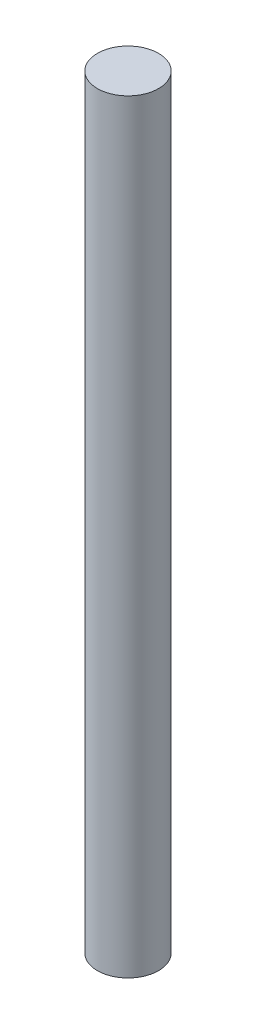
from build123d import *

# Parameters (mm, degrees)
ESQUISSE1_R        = 3
BOSS_EXTRU_1_DEPTH = 75


with BuildPart() as part:
    # Esquisse1 → Boss.-Extru.1 (new body)
    with BuildSketch(Plane(origin=(0, 0, 0), x_dir=(1, 0, 0), z_dir=(0, 1, 0))):
        Circle(ESQUISSE1_R)
    extrude(amount=BOSS_EXTRU_1_DEPTH)


solid = part.part
